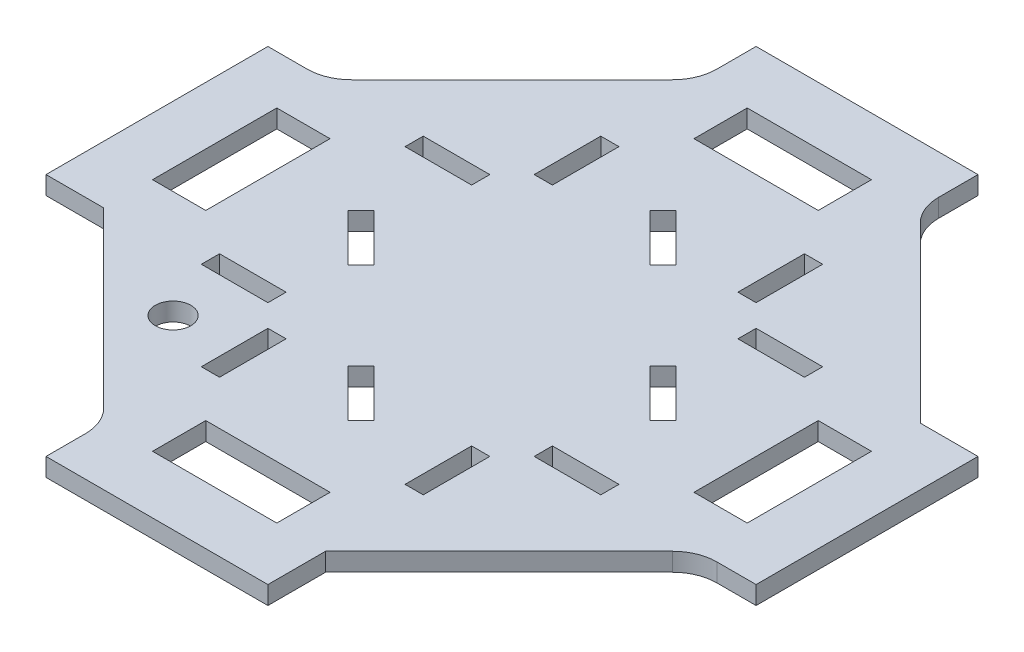
from build123d import *

# Parameters (mm, degrees)
SKETCH1_R           = 4
SKETCH1_W           = 4.1
SKETCH1_H           = 15
SKETCH1_W_2         = 15
SKETCH1_H_2         = 4.1
SKETCH1_W_3         = 12
SKETCH1_H_3         = 28
SKETCH1_W_4         = 28
SKETCH1_H_4         = 12
BOSS_EXTRUDE1_DEPTH = 4.1
FILLET4_R           = 10


with BuildPart() as part:
    # Sketch1 → Boss-Extrude1 (new body)
    with BuildSketch(Plane(origin=(0, 0, 0), x_dir=(1, 0, 0), z_dir=(0, 1, 0))):
        Polygon((-25, 67), (-67, 25), (-80, 25), (-80, -25), (-67, -25), (-25, -67), (-25, -80), (25, -80), (25, -67), (67, -25), (80, -25), (80, 25), (67, 25), (25, 67), (25, 80), (-25, 80), align=None)
        with Locations((-38.183766184, -38.183766184)):
            Circle(SKETCH1_R, mode=Mode.SUBTRACT)
        with Locations((-22.95, 37.5)):
            Rectangle(SKETCH1_W, SKETCH1_H, mode=Mode.SUBTRACT)
        with Locations((-37.5, 22.95)):
            Rectangle(SKETCH1_W_2, SKETCH1_H_2, mode=Mode.SUBTRACT)
        with Locations((37.5, -22.95)):
            Rectangle(SKETCH1_W_2, SKETCH1_H_2, mode=Mode.SUBTRACT)
        with Locations((22.95, -37.5)):
            Rectangle(SKETCH1_W, SKETCH1_H, mode=Mode.SUBTRACT)
        with Locations((37.5, 22.95)):
            Rectangle(SKETCH1_W_2, SKETCH1_H_2, mode=Mode.SUBTRACT)
        with Locations((-37.5, -22.95)):
            Rectangle(SKETCH1_W_2, SKETCH1_H_2, mode=Mode.SUBTRACT)
        with Locations((22.95, 37.5)):
            Rectangle(SKETCH1_W, SKETCH1_H, mode=Mode.SUBTRACT)
        with Locations((-22.95, -37.5)):
            Rectangle(SKETCH1_W, SKETCH1_H, mode=Mode.SUBTRACT)
        Polygon((-36.062445841, 4.949747468), (-25.455844123, -5.656854249), (-28.354981926, -8.555992052), (-38.961583643, 2.050609665), align=None, mode=Mode.SUBTRACT)
        Polygon((-8.555992052, -28.354981926), (2.050609665, -38.961583643), (4.949747468, -36.062445841), (-5.656854249, -25.455844123), align=None, mode=Mode.SUBTRACT)
        with Locations((-61, 0)):
            Rectangle(SKETCH1_W_3, SKETCH1_H_3, mode=Mode.SUBTRACT)
        with Locations((61, 0)):
            Rectangle(SKETCH1_W_3, SKETCH1_H_3, mode=Mode.SUBTRACT)
        with Locations((0, 61)):
            Rectangle(SKETCH1_W_4, SKETCH1_H_4, mode=Mode.SUBTRACT)
        with Locations((0, -61)):
            Rectangle(SKETCH1_W_4, SKETCH1_H_4, mode=Mode.SUBTRACT)
        Polygon((38.961583643, -2.050609665), (36.062445841, -4.949747468), (25.455844123, 5.656854249), (28.354981926, 8.555992052), align=None, mode=Mode.SUBTRACT)
        Polygon((8.555992052, 28.354981926), (-2.050609665, 38.961583643), (-4.949747468, 36.062445841), (5.656854249, 25.455844123), align=None, mode=Mode.SUBTRACT)
    extrude(amount=BOSS_EXTRUDE1_DEPTH)

    # Fillet4
    fillet4_edges = [part.edges().sort_by_distance(p)[0] for p in [
        (-25, 2.05, 67),
        (-67, 2.05, -25),
        (-25, 2.05, -67),
        (25, 2.05, -67),
        (67, 2.05, 25),
    ]]
    fillet(fillet4_edges, radius=FILLET4_R)


solid = part.part
